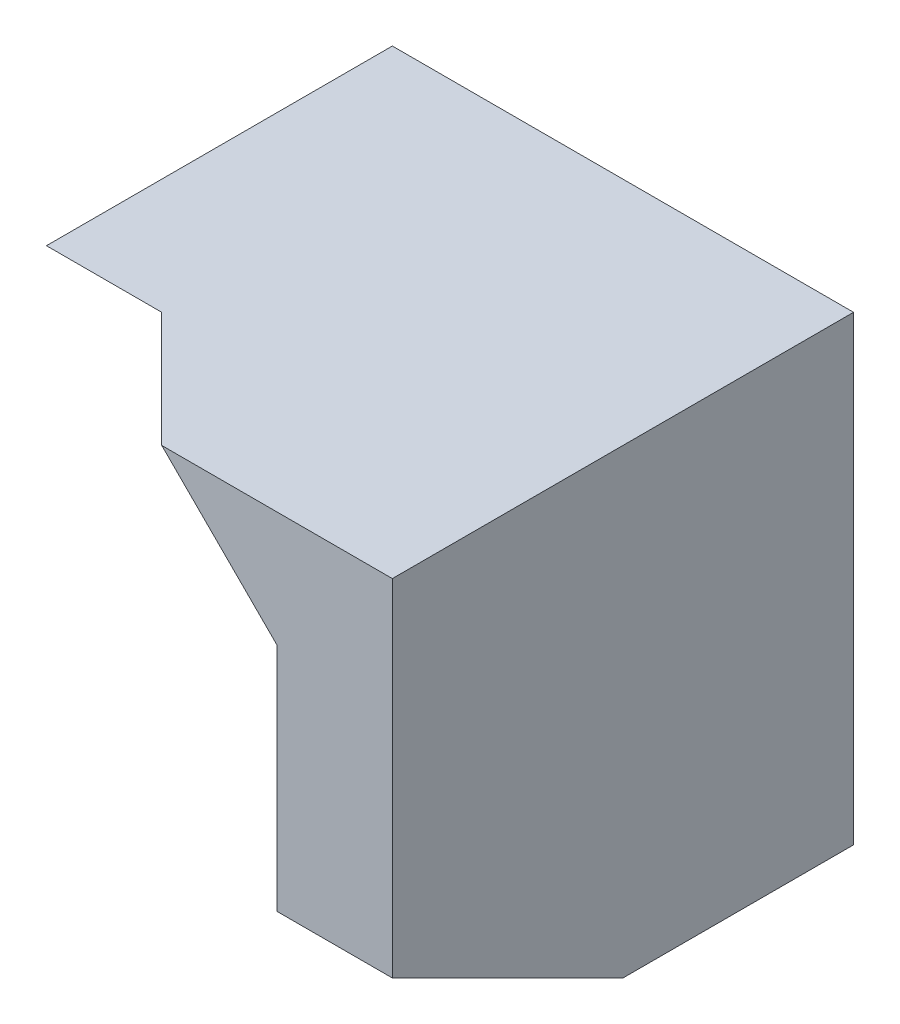
from build123d import *

# Parameters (mm, degrees)
SKETCH1_W            = 40
SKETCH1_H            = 40
BOSS_EXTRUDE1_DEPTH  = 20
CUT_EXTRUDE1_DEPTH   = 20
SKETCH3_W            = 10
SKETCH3_H            = 10
CUT_EXTRUDE2_DEPTH   = 10
BOSS_EXTRUDE2_DEPTH  = 10
BOSS_EXTRUDE3_DEPTH  = 29
BOSS_EXTRUDE4_DEPTH  = 10
CUT_EXTRUDE3_DEPTH   = 10
BOSS_EXTRUDE5_DEPTH  = 10
SKETCH17_W           = 10
SKETCH17_H           = 10
BOSS_EXTRUDE8_DEPTH  = 30
CUT_EXTRUDE4_DEPTH   = 30
CUT_EXTRUDE5_DEPTH   = 10
CUT_EXTRUDE6_DEPTH   = 10
SKETCH21_W           = 5
SKETCH21_H           = 10
BOSS_EXTRUDE9_DEPTH  = 5
CUT_EXTRUDE7_DEPTH   = 5
CUT_EXTRUDE8_DEPTH   = 5
CUT_EXTRUDE9_DEPTH   = 5
BOSS_EXTRUDE10_DEPTH = 5
BOSS_EXTRUDE11_DEPTH = 5
SKETCH27_W           = 20
SKETCH27_H           = 5
BOSS_EXTRUDE12_DEPTH = 40
CUT_EXTRUDE10_DEPTH  = 19


with BuildPart() as part:
    # Sketch1 → Boss-Extrude1 (new body)
    with BuildSketch(Plane.XY):
        with Locations((20, 20)):
            Rectangle(SKETCH1_W, SKETCH1_H)
    extrude(amount=BOSS_EXTRUDE1_DEPTH)

    # Sketch2 → Cut-Extrude1 (cut)
    with BuildSketch(Plane.XY.offset(20)):
        Polygon((0, 0), (30, 0), (10, 20), (0, 20), align=None)
    extrude(amount=-CUT_EXTRUDE1_DEPTH, mode=Mode.SUBTRACT)

    # Sketch3 → Cut-Extrude2 (cut)
    with BuildSketch(Plane.ZY):
        with Locations((15, 25)):
            Rectangle(SKETCH3_W, SKETCH3_H)
    extrude(amount=-CUT_EXTRUDE2_DEPTH, mode=Mode.SUBTRACT)

    # Sketch5 → Boss-Extrude2 (add)
    with BuildSketch(Plane(origin=(40, 0, 0), x_dir=(0, 0, -1), z_dir=(1, 0, 0))):
        Polygon((-20, 40), (-20, 0), (-40, 10), (-40, 40), align=None)
    extrude(amount=-BOSS_EXTRUDE2_DEPTH)

    # Sketch7 → Boss-Extrude3 (add)
    with BuildSketch(Plane.XY.offset(40)):
        Polygon((30, 30), (30, 40), (20, 40), align=None)
    extrude(amount=-BOSS_EXTRUDE3_DEPTH)

    # Sketch8 → Boss-Extrude4 (add)
    with BuildSketch(Plane.ZY):
        Polygon((20, 40), (20, 30), (30, 40), align=None)
    extrude(amount=-BOSS_EXTRUDE4_DEPTH)

    # Sketch9 → Cut-Extrude3 (cut)
    with BuildSketch(Plane.XY.offset(20)):
        Polygon((10, 30), (20, 20), (20, 10), (10, 20), align=None)
    extrude(amount=-CUT_EXTRUDE3_DEPTH, mode=Mode.SUBTRACT)

    # Sketch15 → Boss-Extrude5 (add)
    with BuildSketch(Plane(origin=(6.666666667, 6.666666667, -6.666666667), x_dir=(-0.40824829046386313, -0.40824829046386274, -0.8164965809277261), z_dir=(0.5773502691896262, 0.5773502691896255, -0.5773502691896256))):
        Polygon((-57.154760665, 0), (-57.154760665, 14.142135624), (-32.659863237, 14.142135624), (-32.659863237, -14.142135624), align=None)
    extrude(amount=BOSS_EXTRUDE5_DEPTH)

    # Sketch17 → Boss-Extrude8 (add)
    with BuildSketch(Plane.ZY):
        with Locations((25, 35)):
            Rectangle(SKETCH17_W, SKETCH17_H)
    extrude(amount=-BOSS_EXTRUDE8_DEPTH)

    # Sketch18 → Cut-Extrude4 (cut)
    with BuildSketch(Plane(origin=(0, 40, 0), x_dir=(1, 0, 0), z_dir=(0, 1, 0))):
        Polygon((20, -40), (31.547005384, -34.226497308), (20, -22.679491924), (20, -30), align=None)
    extrude(amount=CUT_EXTRUDE4_DEPTH, mode=Mode.SUBTRACT)

    # Sketch19 → Cut-Extrude5 (cut)
    with BuildSketch(Plane.ZY):
        Polygon((30, 40), (20, 30), (30, 30), align=None)
    extrude(amount=-CUT_EXTRUDE5_DEPTH, mode=Mode.SUBTRACT)

    # Sketch20 → Cut-Extrude6 (cut)
    with BuildSketch(Plane(origin=(6.666666667, 6.666666667, -6.666666667), x_dir=(0.40824829046386324, 0.4082482904638628, 0.816496580927726), z_dir=(-0.5773502691896261, -0.5773502691896254, 0.5773502691896257))):
        Polygon((44.907311951, 7.071067812), (44.907311951, 14.142135624), (32.659863237, 14.142135624), align=None)
    extrude(amount=CUT_EXTRUDE6_DEPTH, mode=Mode.SUBTRACT)

    # Sketch21 → Boss-Extrude9 (add)
    with BuildSketch(Plane(origin=(0, 40, 0), x_dir=(1, 0, 0), z_dir=(0, 1, 0))):
        with Locations((17.5, -35)):
            Rectangle(SKETCH21_W, SKETCH21_H)
    extrude(amount=-BOSS_EXTRUDE9_DEPTH)

    # Sketch22 → Cut-Extrude7 (cut)
    with BuildSketch(Plane(origin=(0, 40, 0), x_dir=(1, 0, 0), z_dir=(0, 1, 0))):
        Polygon((20, -40), (15, -35), (15, -40), align=None)
    extrude(amount=-CUT_EXTRUDE7_DEPTH, mode=Mode.SUBTRACT)

    # Sketch23 → Cut-Extrude8 (cut)
    with BuildSketch(Plane(origin=(6.666666667, 6.666666667, -6.666666667), x_dir=(0.40824829046386324, 0.4082482904638628, 0.816496580927726), z_dir=(-0.5773502691896261, -0.5773502691896254, 0.5773502691896257))):
        Polygon((44.907311951, 14.142135624), (44.907311951, 21.213203436), (32.659863237, 14.142135624), align=None)
    extrude(amount=CUT_EXTRUDE8_DEPTH, mode=Mode.SUBTRACT)


with BuildPart() as cut_extrude8_piece_1:
    # of the separate pieces the step leaves, piece 1, a body of its own (cut_extrude8_pieces)
    add(part.part.solids().sort_by_distance((30, 0, 0))[0])

    # Sketch25 → Boss-Extrude10 (add)
    with BuildSketch(Plane(origin=(0, 40, 0), x_dir=(1, 0, 0), z_dir=(0, 1, 0))):
        Polygon((15, -35), (10, -30), (15, -30), align=None)
    extrude(amount=-BOSS_EXTRUDE10_DEPTH)

    # Sketch26 → Boss-Extrude11 (add)
    with BuildSketch(Plane(origin=(0, 0, 30), x_dir=(-1, 0, 0), z_dir=(0, 0, -1))):
        Polygon((-15, 35), (-10, 40), (-10, 35), align=None)
    extrude(amount=BOSS_EXTRUDE11_DEPTH)

    # Sketch27 → Boss-Extrude12 (add)
    with BuildSketch(Plane(origin=(0, 0, 0), x_dir=(-1, 0, 0), z_dir=(0, 0, -1))):
        with Locations((-30, 37.5)):
            Rectangle(SKETCH27_W, SKETCH27_H)
    extrude(amount=-BOSS_EXTRUDE12_DEPTH)

    # 3DSketch1 → Cut-Extrude10 (cut, along a direction that is not the sketch's normal)
    with BuildSketch(Plane(origin=(10, 30, 20), x_dir=(0.7071067811865477, 0, 0.7071067811865475), z_dir=(0.5773502691896258, 0.5773502691896254, -0.5773502691896261))):
        Polygon((0, 0), (7.071067812, -12.247448714), (21.213203436, -12.247448714), (28.284271247, 0), (14.142135624, 24.494897428), align=None)
    extrude(amount=-CUT_EXTRUDE10_DEPTH, dir=(0, 0, -1), mode=Mode.SUBTRACT)


with BuildPart() as cut_extrude8_piece_2:
    # of the separate pieces the step leaves, piece 2, a body of its own (cut_extrude8_pieces)
    add(part.part.solids().sort_by_distance((10, 30, 30))[0])

    # Sketch24 → Cut-Extrude9 (cut)
    with BuildSketch(Plane(origin=(3.779915321, 3.779915321, -3.779915321), x_dir=(-0.4082482904638635, -0.40824829046386263, -0.816496580927726), z_dir=(0.5773502691896261, 0.5773502691896255, -0.5773502691896258))):
        Polygon((-41.371778045, 14.142135624), (-41.371778045, 15.089479079), (-39.730931049, 14.142135624), align=None)
    extrude(amount=-CUT_EXTRUDE9_DEPTH, mode=Mode.SUBTRACT)


solid = cut_extrude8_piece_1.part
